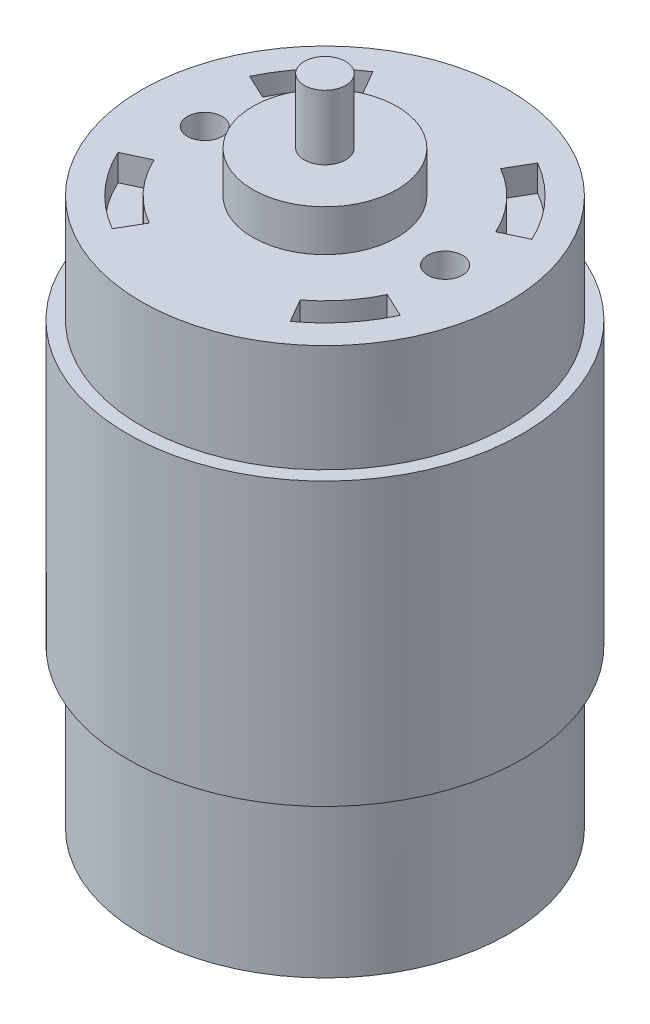
from build123d import *

# Parameters (mm, degrees)
SKETCH2_R            = 22.1488
BOSS_EXTRUDE4_DEPTH  = 66.0908
SKETCH4_R            = 8.6995
BOSS_EXTRUDE5_DEPTH  = 5.0038
SKETCH9_R            = 2.5019
BOSS_EXTRUDE6_DEPTH  = 7.7978
SKETCH10_R           = 8.7503
BOSS_EXTRUDE7_DEPTH  = 6.7056
SKETCH11_R           = 2.5019
BOSS_EXTRUDE8_DEPTH  = 2.413
SKETCH12_R           = 23.8125
BOSS_EXTRUDE9_DEPTH  = 34.0106
SKETCH13_R           = 2.0955
CUT_EXTRUDE1_DEPTH   = 3.175
CUT_EXTRUDE2_DEPTH   = 3.175
SKETCH15_R           = 20.958175
SKETCH15_R_2         = 8.7503
CUT_EXTRUDE3_DEPTH   = 3.175
SKETCH16_R           = 7.1628
SKETCH16_R_2         = 2.5019
CUT_EXTRUDE4_DEPTH   = 2.54
BOSS_EXTRUDE12_DEPTH = 3.175
BOSS_EXTRUDE13_DEPTH = 3.175
SKETCH20_R           = 1.5875
CUT_EXTRUDE5_DEPTH   = 3.175


with BuildPart() as part:
    # Sketch2 → Boss-Extrude4 (new body)
    with BuildSketch(Plane(origin=(0, 0, 0), x_dir=(1, 0, 0), z_dir=(0, 1, 0))):
        Circle(SKETCH2_R)
    extrude(amount=BOSS_EXTRUDE4_DEPTH)

    # Sketch4 → Boss-Extrude5 (add)
    with BuildSketch(Plane(origin=(0, 66.0908, 0), x_dir=(1, 0, 0), z_dir=(0, 1, 0))):
        Circle(SKETCH4_R)
    extrude(amount=BOSS_EXTRUDE5_DEPTH)

    # Sketch9 → Boss-Extrude6 (add)
    with BuildSketch(Plane(origin=(0, 71.0946, 0), x_dir=(1, 0, 0), z_dir=(0, 1, 0))):
        Circle(SKETCH9_R)
    extrude(amount=BOSS_EXTRUDE6_DEPTH)

    # Sketch10 → Boss-Extrude7 (add)
    with BuildSketch(Plane.XZ):
        Circle(SKETCH10_R)
    extrude(amount=BOSS_EXTRUDE7_DEPTH)

    # Sketch11 → Boss-Extrude8 (add)
    with BuildSketch(Plane.XZ.offset(6.7056)):
        Circle(SKETCH11_R)
    extrude(amount=BOSS_EXTRUDE8_DEPTH)

    # Sketch12 → Boss-Extrude9 (add)
    with BuildSketch(Plane(origin=(0, 53.1114, 0), x_dir=(-1, 0, 0), z_dir=(0, -1, 0))):
        Circle(SKETCH12_R)
    extrude(amount=BOSS_EXTRUDE9_DEPTH)

    # Sketch13 → Cut-Extrude1 (cut)
    with BuildSketch(Plane(origin=(0, 66.0908, 0), x_dir=(1, 0, 0), z_dir=(0, 1, 0))):
        with Locations((-14.5034, 0)):
            Circle(SKETCH13_R)
        with Locations((14.5034, 0)):
            Circle(SKETCH13_R)
    extrude(amount=-CUT_EXTRUDE1_DEPTH, mode=Mode.SUBTRACT)

    # Sketch14 → Cut-Extrude2 (cut)
    with BuildSketch(Plane(origin=(0, 66.0908, 0), x_dir=(1, 0, 0), z_dir=(0, 1, 0))):
        with BuildLine():
            Line((-14.070005184, -6.560951168), (-17.033311719, -7.942763698))
            ThreePointArc((-17.033311719, -7.942763698), (-13.856523006, -12.697163994), (-9.397090019, -16.276237356))
            Line((-9.397090019, -16.276237356), (-7.76226652, -13.444639995))
            ThreePointArc((-7.76226652, -13.444639995), (-11.445886375, -10.4882225), (-14.070005184, -6.560951168))
        make_face()
        with BuildLine():
            ThreePointArc((-10.080336815, 15.862156631), (-14.123267338, 12.399779151), (-17.033311719, 7.942763698))
            Line((-17.033311719, 7.942763698), (-14.070005184, 6.560951168))
            ThreePointArc((-14.070005184, 6.560951168), (-11.711998853, 10.190201616), (-8.44372295, 13.027458265))
            Line((-8.44372295, 13.027458265), (-10.080336815, 15.862156631))
        make_face()
        with BuildLine():
            ThreePointArc((17.033311719, 7.942763698), (13.856523006, 12.697163994), (9.397090019, 16.276237356))
            Line((9.397090019, 16.276237356), (7.76226652, 13.444639995))
            ThreePointArc((7.76226652, 13.444639995), (11.445886375, 10.4882225), (14.070005184, 6.560951168))
            Line((14.070005184, 6.560951168), (17.033311719, 7.942763698))
        make_face()
        with BuildLine():
            Line((9.385927189, -12.365900571), (11.031460095, -15.21604717))
            ThreePointArc((11.031460095, -15.21604717), (14.495965555, -11.961947414), (17.033311719, -7.942763698))
            Line((17.033311719, -7.942763698), (14.070005184, -6.560951168))
            ThreePointArc((14.070005184, -6.560951168), (12.081785889, -9.748926908), (9.385927189, -12.365900571))
        make_face()
    extrude(amount=-CUT_EXTRUDE2_DEPTH, mode=Mode.SUBTRACT)

    # Sketch15 → Cut-Extrude3 (cut)
    with BuildSketch(Plane.XZ):
        Circle(SKETCH15_R)
        Circle(SKETCH15_R_2, mode=Mode.SUBTRACT)
    extrude(amount=-CUT_EXTRUDE3_DEPTH, mode=Mode.SUBTRACT)

    # Sketch16 → Cut-Extrude4 (cut)
    with BuildSketch(Plane.XZ.offset(6.7056)):
        Circle(SKETCH16_R)
        Circle(SKETCH16_R_2, mode=Mode.SUBTRACT)
    extrude(amount=-CUT_EXTRUDE4_DEPTH, mode=Mode.SUBTRACT)

    # Sketch18 → Boss-Extrude12 (add)
    with BuildSketch(Plane.XZ):
        with BuildLine():
            ThreePointArc((20.865163654, 0), (20.780212376, 1.88091146), (20.52605029, 3.746506881))
            Line((20.52605029, 3.746506881), (17.399, 3.746506881))
            Line((17.399, 3.746506881), (17.399, -2.603493119))
            Line((17.399, -2.603493119), (20.702098393, -2.603493119))
            ThreePointArc((20.702098393, -2.603493119), (20.824357436, -1.304297387), (20.865163654, 0))
        make_face()
    extrude(amount=-BOSS_EXTRUDE12_DEPTH)

    # Sketch19 → Boss-Extrude13 (add)
    with BuildSketch(Plane(origin=(0, 0, 0), x_dir=(-1, 0, 0), z_dir=(0, -1, 0))):
        with BuildLine():
            Line((20.716285244, -3.175), (17.399, -3.175))
            Line((17.399, -3.175), (17.399, 3.175))
            Line((17.399, 3.175), (20.716285244, 3.175))
            ThreePointArc((20.716285244, 3.175), (20.958175, 0), (20.716285244, -3.175))
        make_face()
    extrude(amount=-BOSS_EXTRUDE13_DEPTH)

    # Sketch20 → Cut-Extrude5 (cut)
    with BuildSketch(Plane(origin=(0, 3.175, 0), x_dir=(-1, 0, 0), z_dir=(0, -1, 0))):
        with Locations((-15.1765, 6.730993119)):
            Circle(SKETCH20_R)
    extrude(amount=-CUT_EXTRUDE5_DEPTH, mode=Mode.SUBTRACT)


solid = part.part
